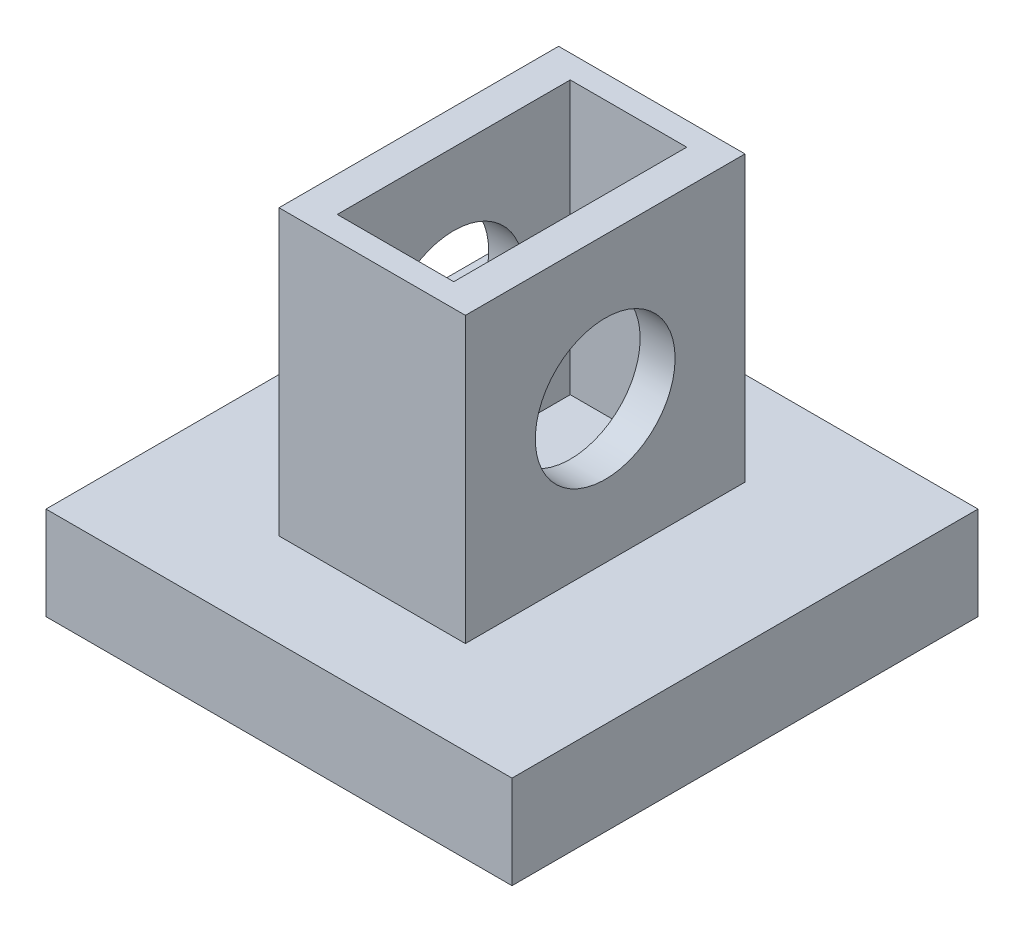
from build123d import *

# Parameters (mm, degrees)
SKETCH2_W           = 42
SKETCH2_H           = 16
BOSS_EXTRUDE1_DEPTH = 4
SKETCH9_W           = 8
SKETCH9_H           = 12
BOSS_EXTRUDE3_DEPTH = 12.2
SKETCH10_W          = 5
SKETCH10_H          = 10
CUT_EXTRUDE6_DEPTH  = 11.7
SKETCH12_R          = 3
CUT_EXTRUDE7_DEPTH  = 8
SKETCH17_W          = 42
SKETCH17_H          = 4
BOSS_EXTRUDE4_DEPTH = 4
SKETCH21_W          = 20
SKETCH21_H          = 4
CUT_EXTRUDE8_DEPTH  = 11
SKETCH22_W          = 20
SKETCH22_H          = 4
CUT_EXTRUDE9_DEPTH  = 11


with BuildPart() as part:
    # Sketch2 → Boss-Extrude1 (new body)
    with BuildSketch(Plane(origin=(0, 0, 0), x_dir=(1, 0, 0), z_dir=(0, 1, 0))):
        with Locations((-19.403711124, -12.332190114)):
            Rectangle(SKETCH2_W, SKETCH2_H)
    extrude(amount=BOSS_EXTRUDE1_DEPTH)

    # Sketch9 → Boss-Extrude3 (add)
    with BuildSketch(Plane(origin=(0, 4, 0), x_dir=(1, 0, 0), z_dir=(0, 1, 0))):
        with Locations((-19.403711124, -14.332190114)):
            Rectangle(SKETCH9_W, SKETCH9_H)
    extrude(amount=BOSS_EXTRUDE3_DEPTH)

    # Sketch10 → Cut-Extrude6 (cut)
    with BuildSketch(Plane(origin=(0, 16.2, 0), x_dir=(1, 0, 0), z_dir=(0, 1, 0))):
        with Locations((-19.403711124, -14.332190114)):
            Rectangle(SKETCH10_W, SKETCH10_H)
    extrude(amount=-CUT_EXTRUDE6_DEPTH, mode=Mode.SUBTRACT)

    # Sketch12 → Cut-Extrude7 (cut)
    with BuildSketch(Plane(origin=(-15.403711124, 0, 0), x_dir=(0, 0, -1), z_dir=(1, 0, 0))):
        with Locations((-14.332190114, 10.1)):
            Circle(SKETCH12_R)
    extrude(amount=-CUT_EXTRUDE7_DEPTH, mode=Mode.SUBTRACT)

    # Sketch17 → Boss-Extrude4 (add)
    with BuildSketch(Plane.XY.offset(20.332190114)):
        with Locations((-19.403711124, 2)):
            Rectangle(SKETCH17_W, SKETCH17_H)
    extrude(amount=BOSS_EXTRUDE4_DEPTH)

    # Sketch21 → Cut-Extrude8 (cut)
    with BuildSketch(Plane.ZY.offset(40.403711124)):
        with Locations((14.332190114, 2)):
            Rectangle(SKETCH21_W, SKETCH21_H)
    extrude(amount=-CUT_EXTRUDE8_DEPTH, mode=Mode.SUBTRACT)

    # Sketch22 → Cut-Extrude9 (cut)
    with BuildSketch(Plane(origin=(1.596288876, 0, 0), x_dir=(0, 0, -1), z_dir=(1, 0, 0))):
        with Locations((-14.332190114, 2)):
            Rectangle(SKETCH22_W, SKETCH22_H)
    extrude(amount=-CUT_EXTRUDE9_DEPTH, mode=Mode.SUBTRACT)


solid = part.part
